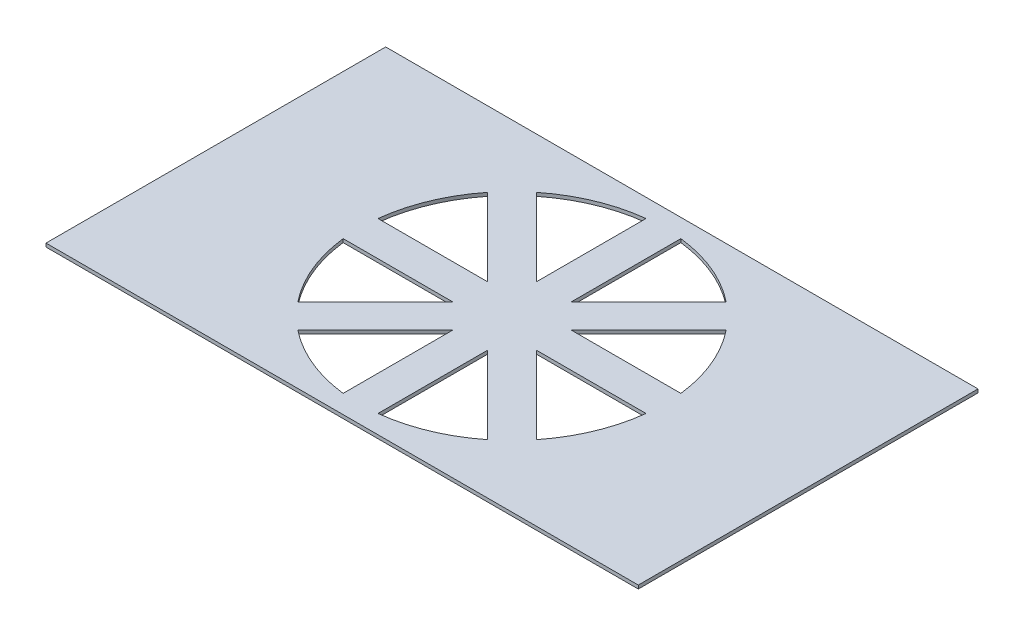
from build123d import *

# Parameters (mm, degrees)
SKETCH1_W           = 68
SKETCH1_H           = 39
BOSS_EXTRUDE1_DEPTH = 0.4


with BuildPart() as part:
    # Sketch1 → Boss-Extrude1 (new body)
    with BuildSketch(Plane(origin=(0, 0, 0), x_dir=(1, 0, 0), z_dir=(0, 1, 0))):
        with Locations((34, 19.5)):
            Rectangle(SKETCH1_W, SKETCH1_H)
        with BuildLine():
            ThreePointArc((20.292495584, 30.379077291), (17.832108181, 26.196960066), (16.614661349, 21.5))
            Line((16.614661349, 21.5), (29.171572875, 21.5))
            Line((29.171572875, 21.5), (20.292495584, 30.379077291))
        make_face(mode=Mode.SUBTRACT)
        with BuildLine():
            ThreePointArc((32, 36.885338651), (27.303039934, 35.667891819), (23.120922709, 33.207504416))
            Line((23.120922709, 33.207504416), (32, 24.328427125))
            Line((32, 24.328427125), (32, 36.885338651))
        make_face(mode=Mode.SUBTRACT)
        with BuildLine():
            ThreePointArc((44.879077291, 33.207504416), (40.696960066, 35.667891819), (36, 36.885338651))
            Line((36, 36.885338651), (36, 24.328427125))
            Line((36, 24.328427125), (44.879077291, 33.207504416))
        make_face(mode=Mode.SUBTRACT)
        with BuildLine():
            ThreePointArc((51.385338651, 21.5), (50.167891819, 26.196960066), (47.707504416, 30.379077291))
            Line((47.707504416, 30.379077291), (38.828427125, 21.5))
            Line((38.828427125, 21.5), (51.385338651, 21.5))
        make_face(mode=Mode.SUBTRACT)
        with BuildLine():
            ThreePointArc((47.707504416, 8.620922709), (50.167891819, 12.803039934), (51.385338651, 17.5))
            Line((51.385338651, 17.5), (38.828427125, 17.5))
            Line((38.828427125, 17.5), (47.707504416, 8.620922709))
        make_face(mode=Mode.SUBTRACT)
        with BuildLine():
            ThreePointArc((36, 2.114661349), (40.696960066, 3.332108181), (44.879077291, 5.792495584))
            Line((44.879077291, 5.792495584), (36, 14.671572875))
            Line((36, 14.671572875), (36, 2.114661349))
        make_face(mode=Mode.SUBTRACT)
        with BuildLine():
            ThreePointArc((23.120922709, 5.792495584), (27.303039934, 3.332108181), (32, 2.114661349))
            Line((32, 2.114661349), (32, 14.671572875))
            Line((32, 14.671572875), (23.120922709, 5.792495584))
        make_face(mode=Mode.SUBTRACT)
        with BuildLine():
            ThreePointArc((16.614661349, 17.5), (17.832108181, 12.803039934), (20.292495584, 8.620922709))
            Line((20.292495584, 8.620922709), (29.171572875, 17.5))
            Line((29.171572875, 17.5), (16.614661349, 17.5))
        make_face(mode=Mode.SUBTRACT)
    extrude(amount=BOSS_EXTRUDE1_DEPTH)


solid = part.part
